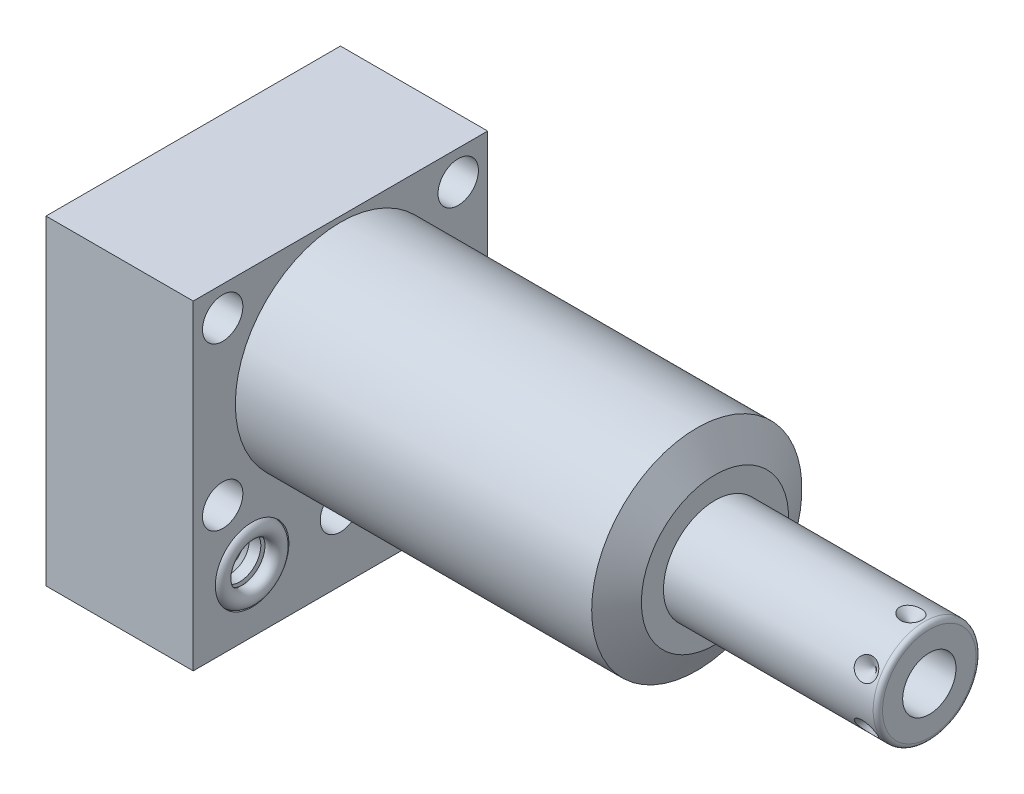
from build123d import *

# Parameters (mm, degrees)
SKETCH1_W           = 63.5
SKETCH1_H           = 69.088
EXTRUDE1_DEPTH      = 80.772
EXTRUDE1_DEPTH_BACK = 31.75
CUT_EXTRUDE1_REACH  = 82.772
SKETCH2_W           = 63.5
SKETCH2_H           = 69.088
SKETCH2_R           = 22.6695
SKETCH18_R          = 7.9375
CUT_EXTRUDE2_DEPTH  = 2.667
SKETCH19_R          = 7.9375
CUT_EXTRUDE3_DEPTH  = 2.667
SKETCH20_R          = 9.525
CUT_EXTRUDE4_DEPTH  = 0.254
SKETCH14_R          = 1.7653
SKETCH15_R          = 1.7653
CIRPATTERN1_COUNT   = 6
SKETCH21_W          = 4.3561
SKETCH21_H          = 31.75
HOLE1_AT_2_COUNT    = 2
HOLE1_AT_2_PITCH    = 54.58107178
HOLE1_AT_3_COUNT    = 2
HOLE1_AT_3_PITCH    = 34.9504
HOLE1_AT_4_COUNT    = 2
HOLE1_AT_4_PITCH    = 50.8
HOLE1_AT_5_COUNT    = 2
HOLE1_AT_5_PITCH    = 61.661742273
LPATTERN1_COUNT     = 2
LPATTERN1_PITCH     = 38.1


with BuildPart() as part:
    # Sketch1 → Extrude1 (new body, two sides)
    with BuildSketch(Plane(origin=(0, 0, 0), x_dir=(0, 0, -1), z_dir=(1, 0, 0))) as extrude1_sk:
        with Locations((0, -10.7188)):
            Rectangle(SKETCH1_W, SKETCH1_H)
    extrude(amount=EXTRUDE1_DEPTH)
    extrude(extrude1_sk.sketch, amount=-EXTRUDE1_DEPTH_BACK)

    # Sketch2 → Cut-Extrude1 (cut, up to next)
    with BuildSketch(Plane(origin=(0, 0, 0), x_dir=(0, 0, -1), z_dir=(1, 0, 0)), mode=Mode.PRIVATE) as cut_extrude1_sk1:
        with Locations((0, -10.7188)):
            Rectangle(SKETCH2_W, SKETCH2_H)
        Circle(SKETCH2_R, mode=Mode.SUBTRACT)
    cut_extrude1_tool1 = extrude(cut_extrude1_sk1.sketch, amount=CUT_EXTRUDE1_REACH, mode=Mode.PRIVATE) & part.part
    add(cut_extrude1_tool1.solids().sort_by_distance((0, 22.886829, 0))[0], mode=Mode.SUBTRACT)

    # Sketch3 → Cut-Revolve1 (revolve, cut)
    with BuildSketch(Plane.XY, mode=Mode.PRIVATE) as cut_revolve1_sk:
        Polygon((76.849193596, 22.6695), (80.772, 15.875), (80.772, 22.6695), align=None)
    revolve(cut_revolve1_sk.sketch.rotate(Axis((76.037136009, 0, 0), (1, 0, 0)), 90), axis=Axis((76.037136009, 0, 0), (1, 0, 0)), mode=Mode.SUBTRACT)  # turned: the seam where the file's is

    # S2D0002 → Cut-Revolve2 (revolve, cut)
    with BuildSketch(Plane(origin=(-29.083, -31.75, 19.05), x_dir=(0, 1, 0), z_dir=(0, 0, 1)), mode=Mode.PRIVATE) as cut_revolve2_sk:
        Polygon((0, 0), (4.5466, 0), (4.106586662, -2.0701), (3.4544, -2.722286662), (3.4544, -13.97), (0, -13.97), align=None)
    revolve(cut_revolve2_sk.sketch.rotate(Axis((-14.4145, -31.75, 19.05), (-1, 0, 0)), 90), axis=Axis((-14.4145, -31.75, 19.05), (-1, 0, 0)), mode=Mode.SUBTRACT)  # turned: the seam where the file's is

    # Sketch5 → Cut-Revolve3 (revolve, cut)
    with BuildSketch(Plane(origin=(-29.083, -31.75, -19.05), x_dir=(0, 1, 0), z_dir=(0, 0, 1)), mode=Mode.PRIVATE) as cut_revolve3_sk:
        Polygon((0, 0), (4.5466, 0), (4.106586662, -2.0701), (3.4544, -2.722286662), (3.4544, -13.97), (0, -13.97), align=None)
    revolve(cut_revolve3_sk.sketch.rotate(Axis((-14.4145, -31.75, -19.05), (-1, 0, 0)), 90), axis=Axis((-14.4145, -31.75, -19.05), (-1, 0, 0)), mode=Mode.SUBTRACT)  # turned: the seam where the file's is

    # Sketch6 → Cut-Revolve4 (revolve, cut)
    with BuildSketch(Plane(origin=(-2.667, -31.75, 19.05), x_dir=(0, -1, 0), z_dir=(0, 0, 1)), mode=Mode.PRIVATE) as cut_revolve4_sk:
        Polygon((0, 0), (4.5466, 0), (4.106586662, -2.0701), (3.4544, -2.722286662), (3.4544, -12.192), (0, -12.192), align=None)
    revolve(cut_revolve4_sk.sketch.rotate(Axis((-15.4686, -31.75, 19.05), (1, 0, 0)), 90), axis=Axis((-15.4686, -31.75, 19.05), (1, 0, 0)), mode=Mode.SUBTRACT)  # turned: the seam where the file's is

    # Sketch7 → Cut-Revolve5 (revolve, cut)
    with BuildSketch(Plane(origin=(-2.667, -31.75, -19.05), x_dir=(0, -1, 0), z_dir=(0, 0, 1)), mode=Mode.PRIVATE) as cut_revolve5_sk:
        Polygon((0, 0), (4.5466, 0), (4.106586662, -2.0701), (3.4544, -2.722286662), (3.4544, -12.192), (0, -12.192), align=None)
    revolve(cut_revolve5_sk.sketch.rotate(Axis((-15.4686, -31.75, -19.05), (1, 0, 0)), 90), axis=Axis((-15.4686, -31.75, -19.05), (1, 0, 0)), mode=Mode.SUBTRACT)  # turned: the seam where the file's is

    # Sketch8 → Cut-Revolve6 (revolve, cut)
    with BuildSketch(Plane(origin=(-15.875, -51.6128, 19.05), x_dir=(-1, 0, 0), z_dir=(0, 0, 1)), mode=Mode.PRIVATE) as cut_revolve6_sk:
        Polygon((0, -6.604), (6.1849, -6.604), (5.642306865, -9.1567), (4.9784, -9.820606865), (4.9784, -25.654), (0, -25.654), align=None)
    revolve(cut_revolve6_sk.sketch.rotate(Axis((-15.875, -24.9428, 19.05), (0, -1, 0)), 270), axis=Axis((-15.875, -24.9428, 19.05), (0, -1, 0)), mode=Mode.SUBTRACT)  # turned: the seam where the file's is

    # Sketch9 → Cut-Revolve7 (revolve, cut)
    with BuildSketch(Plane(origin=(-15.875, -51.6128, -19.05), x_dir=(-1, 0, 0), z_dir=(0, 0, 1)), mode=Mode.PRIVATE) as cut_revolve7_sk:
        Polygon((0, -6.604), (6.1849, -6.604), (5.642306865, -9.1567), (4.9784, -9.820606865), (4.9784, -25.654), (0, -25.654), align=None)
    revolve(cut_revolve7_sk.sketch.rotate(Axis((-15.875, -24.9428, -19.05), (0, -1, 0)), 270), axis=Axis((-15.875, -24.9428, -19.05), (0, -1, 0)), mode=Mode.SUBTRACT)  # turned: the seam where the file's is

    # Sketch18 → Cut-Extrude2 (cut)
    with BuildSketch(Plane(origin=(0, 0, 0), x_dir=(0, 0, -1), z_dir=(1, 0, 0))):
        with Locations((-19.05, -31.75)):
            Circle(SKETCH18_R)
        with Locations((19.05, -31.75)):
            Circle(SKETCH18_R)
    extrude(amount=-CUT_EXTRUDE2_DEPTH, mode=Mode.SUBTRACT)

    # Sketch19 → Cut-Extrude3 (cut)
    with BuildSketch(Plane.ZY.offset(31.75)):
        with Locations(Location((-19.05, -31.75, 0), (0, 0, 180))):  # turned: the seam where the file's is
            Circle(SKETCH19_R)
        with Locations(Location((19.05, -31.75, 0), (0, 0, 180))):  # turned: the seam where the file's is
            Circle(SKETCH19_R)
    extrude(amount=-CUT_EXTRUDE3_DEPTH, mode=Mode.SUBTRACT)

    # Sketch20 → Cut-Extrude4 (cut)
    with BuildSketch(Plane.XZ.offset(45.2628)):
        with Locations(Location((-15.875, -19.05, 0), (0, 0, 270))):  # turned: the seam where the file's is
            Circle(SKETCH20_R)
        with Locations(Location((-15.875, 19.05, 0), (0, 0, 270))):  # turned: the seam where the file's is
            Circle(SKETCH20_R)
    extrude(amount=-CUT_EXTRUDE4_DEPTH, mode=Mode.SUBTRACT)

    # Sketch10 → Revolve1 (revolve)
    with BuildSketch(Plane.XY, mode=Mode.PRIVATE) as revolve1_sk:
        with BuildLine():
            Line((80.772, 0), (80.772, 11.1125))
            Line((80.772, 11.1125), (125.984, 11.1125))
            ThreePointArc((125.984, 11.1125), (126.70242049, 10.81492049), (127, 10.0965))
            Line((127, 10.0965), (127, 0))
            Line((127, 0), (80.772, 0))
        make_face()
    revolve(revolve1_sk.sketch.rotate(Axis((58.270820274, 0, 0), (1, 0, 0)), 90), axis=Axis((58.270820274, 0, 0), (1, 0, 0)))  # turned: the seam where the file's is

    # S2D0001 → Cut-Revolve8 (revolve, cut)
    with BuildSketch(Plane(origin=(118.6434, -5.7531, 0), x_dir=(0, -1, 0), z_dir=(0, 0, 1)), mode=Mode.PRIVATE) as cut_revolve8_sk:
        Polygon((0, 8.3566), (0, -8.6614), (-5.7531, -12.118211227), (-5.7531, 8.3566), align=None)
    revolve(cut_revolve8_sk.sketch.rotate(Axis((84.296273767, 0, 0), (1, 0, 0)), 270), axis=Axis((84.296273767, 0, 0), (1, 0, 0)), mode=Mode.SUBTRACT)  # turned: the seam where the file's is

    # Sketch16 → Cut-Revolve9 (revolve, cut)
    with BuildSketch(Plane(origin=(114.681, -11.1125, 0), x_dir=(-1, 0, 0), z_dir=(0, 0, 1)), mode=Mode.PRIVATE) as cut_revolve9_sk:
        Polygon((-8.3566, 0), (-5.9436, 0), (-8.3566, -2.413), align=None)
    cut_revolve9 = revolve(cut_revolve9_sk.sketch.rotate(Axis((123.0376, -6.093194843, 0), (0, -1, 0)), 90), axis=Axis((123.0376, -6.093194843, 0), (0, -1, 0)), mode=Mode.SUBTRACT)  # turned: the seam where the file's is

    # CirPattern1: Cut-Revolve9 ×6 about axis
    cirpattern1_axis = Axis((0, 0, 0), (-1, 0, 0))
    for i in range(1, CIRPATTERN1_COUNT):
        add(cut_revolve9.rotate(cirpattern1_axis, i * 360 / CIRPATTERN1_COUNT), mode=Mode.SUBTRACT)

    # Sketch21 → Hole1 (revolve, cut)
    with BuildSketch(Plane(origin=(0, 17.4752, 25.4), x_dir=(0, 0, -1), z_dir=(0, 1, 0))):
        with Locations((2.17805, 15.875)):
            Rectangle(SKETCH21_W, SKETCH21_H)
    hole1 = revolve(axis=Axis((-110, 17.4752, 25.4), (1, 0, 0)), mode=Mode.SUBTRACT)

    # Hole1 at 2: Hole1 ×2
    with Locations(*[Vector(0, -0.885120032, -0.465362793) * (i * HOLE1_AT_2_PITCH) for i in range(1, HOLE1_AT_2_COUNT)]):
        add(hole1, mode=Mode.SUBTRACT)

    # Hole1 at 3: Hole1 ×2
    with Locations(*[(0, -i * HOLE1_AT_3_PITCH, 0) for i in range(1, HOLE1_AT_3_COUNT)]):
        add(hole1, mode=Mode.SUBTRACT)

    # Hole1 at 4: Hole1 ×2
    with Locations(*[(0, 0, -i * HOLE1_AT_4_PITCH) for i in range(1, HOLE1_AT_4_COUNT)]):
        add(hole1, mode=Mode.SUBTRACT)

    # Hole1 at 5: Hole1 ×2
    with Locations(*[Vector(0, -0.566808506, -0.823849572) * (i * HOLE1_AT_5_PITCH) for i in range(1, HOLE1_AT_5_COUNT)]):
        add(hole1, mode=Mode.SUBTRACT)


with BuildPart() as body_2:
    # Sketch14 → Revolve2 (revolve)
    with BuildSketch(Plane(origin=(0, -31.75, -19.05), x_dir=(0, 0, -1), z_dir=(0, -1, 0)), mode=Mode.PRIVATE) as revolve2_sk:
        with Locations((6.1722, -0.9017)):
            Circle(SKETCH14_R)
    revolve2 = revolve(revolve2_sk.sketch.rotate(Axis((-2.84353, -31.75, -19.05), (1, 0, 0)), 180), axis=Axis((-2.84353, -31.75, -19.05), (1, 0, 0)))  # turned: the seam where the file's is


with BuildPart() as body_3:
    # Sketch15 → Revolve3 (revolve)
    with BuildSketch(Plane(origin=(0, -31.75, -19.05), x_dir=(0, 0, -1), z_dir=(0, -1, 0)), mode=Mode.PRIVATE) as revolve3_sk:
        with Locations((6.1722, -30.8483)):
            Circle(SKETCH15_R)
    revolve3 = revolve(revolve3_sk.sketch.rotate(Axis((-32.79013, -31.75, -19.05), (1, 0, 0)), 180), axis=Axis((-32.79013, -31.75, -19.05), (1, 0, 0)))  # turned: the seam where the file's is


with BuildPart() as lpattern1_1:
    # LPattern1: Revolve2, Revolve3 ×2
    with Locations(*[(0, 0, i * LPATTERN1_PITCH) for i in range(1, LPATTERN1_COUNT)]):
        add(revolve2)
        add(revolve3)


solid = Compound([part.part, body_2.part, body_3.part, lpattern1_1.part])
